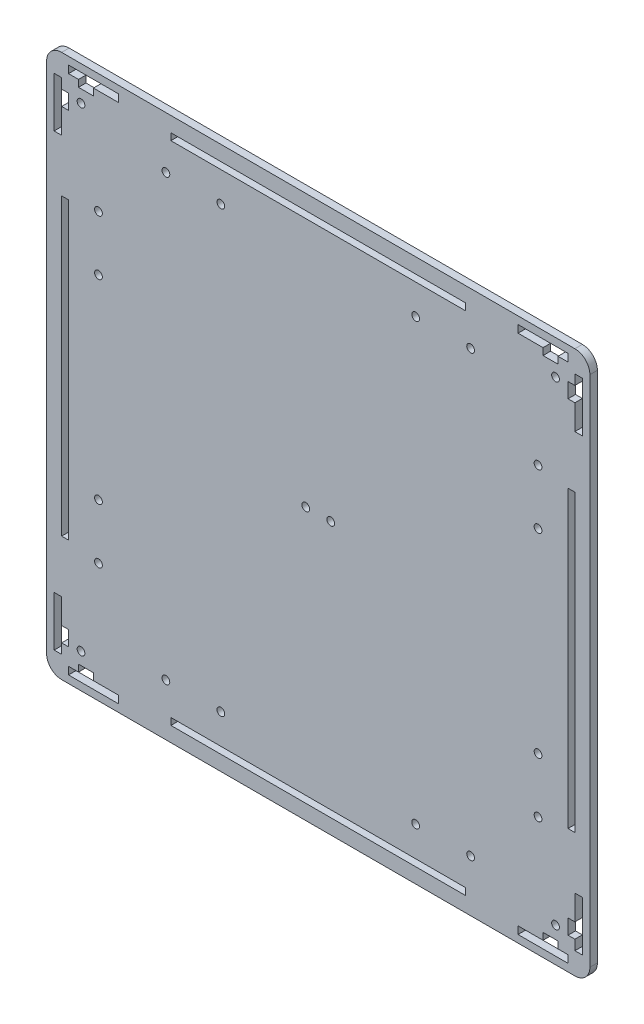
from build123d import *

# Parameters (mm, degrees)
SKETCH_1_R      = 1.55
SKETCH_1_W      = 118
SKETCH_1_H      = 2.75
SKETCH_1_W_2    = 2.75
SKETCH_1_H_2    = 118
EXTRUDE_2_DEPTH = 3


with BuildPart() as part:
    # 草图1 → 凸台-拉伸2 (new body)
    with BuildSketch(Plane.XY):
        with BuildLine():
            Line((208.75, -2.75), (208.75, 202.75))
            ThreePointArc((208.75, 202.75), (206.992640687, 206.992640687), (202.75, 208.75))
            Line((202.75, 208.75), (-2.75, 208.75))
            ThreePointArc((-2.75, 208.75), (-6.992640687, 206.992640687), (-8.75, 202.75))
            Line((-8.75, 202.75), (-8.75, -2.75))
            ThreePointArc((-8.75, -2.75), (-6.992640687, -6.992640687), (-2.75, -8.75))
            Line((-2.75, -8.75), (202.75, -8.75))
            ThreePointArc((202.75, -8.75), (206.992640687, -6.992640687), (208.75, -2.75))
        make_face()
        with Locations((5, 195)):
            Circle(SKETCH_1_R, mode=Mode.SUBTRACT)
        with Locations((195, 195)):
            Circle(SKETCH_1_R, mode=Mode.SUBTRACT)
        with Locations((195, 5)):
            Circle(SKETCH_1_R, mode=Mode.SUBTRACT)
        with Locations((5, 5)):
            Circle(SKETCH_1_R, mode=Mode.SUBTRACT)
        with Locations((95, 100)):
            Circle(SKETCH_1_R, mode=Mode.SUBTRACT)
        with Locations((105, 100)):
            Circle(SKETCH_1_R, mode=Mode.SUBTRACT)
        with Locations((39, 12)):
            Circle(SKETCH_1_R, mode=Mode.SUBTRACT)
        with Locations((61, 12)):
            Circle(SKETCH_1_R, mode=Mode.SUBTRACT)
        with Locations((139, 12)):
            Circle(SKETCH_1_R, mode=Mode.SUBTRACT)
        with Locations((161, 12)):
            Circle(SKETCH_1_R, mode=Mode.SUBTRACT)
        with Locations((188, 39)):
            Circle(SKETCH_1_R, mode=Mode.SUBTRACT)
        with Locations((188, 61)):
            Circle(SKETCH_1_R, mode=Mode.SUBTRACT)
        with Locations((188, 161)):
            Circle(SKETCH_1_R, mode=Mode.SUBTRACT)
        with Locations((188, 139)):
            Circle(SKETCH_1_R, mode=Mode.SUBTRACT)
        with Locations((39, 188)):
            Circle(SKETCH_1_R, mode=Mode.SUBTRACT)
        with Locations((61, 188)):
            Circle(SKETCH_1_R, mode=Mode.SUBTRACT)
        with Locations((139, 188)):
            Circle(SKETCH_1_R, mode=Mode.SUBTRACT)
        with Locations((161, 188)):
            Circle(SKETCH_1_R, mode=Mode.SUBTRACT)
        with Locations((12, 161)):
            Circle(SKETCH_1_R, mode=Mode.SUBTRACT)
        with Locations((12, 139)):
            Circle(SKETCH_1_R, mode=Mode.SUBTRACT)
        with Locations((12, 61)):
            Circle(SKETCH_1_R, mode=Mode.SUBTRACT)
        with Locations((12, 39)):
            Circle(SKETCH_1_R, mode=Mode.SUBTRACT)
        Polygon((0, 202.75), (0, 205.75), (20, 205.75), (20, 202.75), (10, 202.75), (10, 200), (4, 200), (4, 202.75), align=None, mode=Mode.SUBTRACT)
        Polygon((4, 0), (10, 0), (10, -2.75), (20, -2.75), (20, -5.75), (0, -5.75), (0, -2.75), (4, -2.75), align=None, mode=Mode.SUBTRACT)
        Polygon((0, 4), (0, 10), (-2.75, 10), (-2.75, 20), (-5.75, 20), (-5.75, 0), (-2.75, 0), (-2.75, 4), align=None, mode=Mode.SUBTRACT)
        Polygon((200, 4), (200, 10), (202.75, 10), (202.75, 20), (205.75, 20), (205.75, 0), (202.75, 0), (202.75, 4), align=None, mode=Mode.SUBTRACT)
        Polygon((200, 202.75), (200, 205.75), (180, 205.75), (180, 202.75), (190, 202.75), (190, 200), (196, 200), (196, 202.75), align=None, mode=Mode.SUBTRACT)
        Polygon((202.75, 200), (205.75, 200), (205.75, 180), (202.75, 180), (202.75, 190), (200, 190), (200, 196), (202.75, 196), align=None, mode=Mode.SUBTRACT)
        Polygon((200, -2.75), (200, -5.75), (180, -5.75), (180, -2.75), (190, -2.75), (190, 0), (196, 0), (196, -2.75), align=None, mode=Mode.SUBTRACT)
        with Locations((100, -1.375)):
            Rectangle(SKETCH_1_W, SKETCH_1_H, mode=Mode.SUBTRACT)
        with Locations((201.375, 100)):
            Rectangle(SKETCH_1_W_2, SKETCH_1_H_2, mode=Mode.SUBTRACT)
        with Locations((100, 201.375)):
            Rectangle(SKETCH_1_W, SKETCH_1_H, mode=Mode.SUBTRACT)
        Polygon((-2.75, 200), (-5.75, 200), (-5.75, 180), (-2.75, 180), (-2.75, 190), (0, 190), (0, 196), (-2.75, 196), align=None, mode=Mode.SUBTRACT)
        with Locations((-1.375, 100)):
            Rectangle(SKETCH_1_W_2, SKETCH_1_H_2, mode=Mode.SUBTRACT)
    extrude(amount=EXTRUDE_2_DEPTH)


solid = part.part
